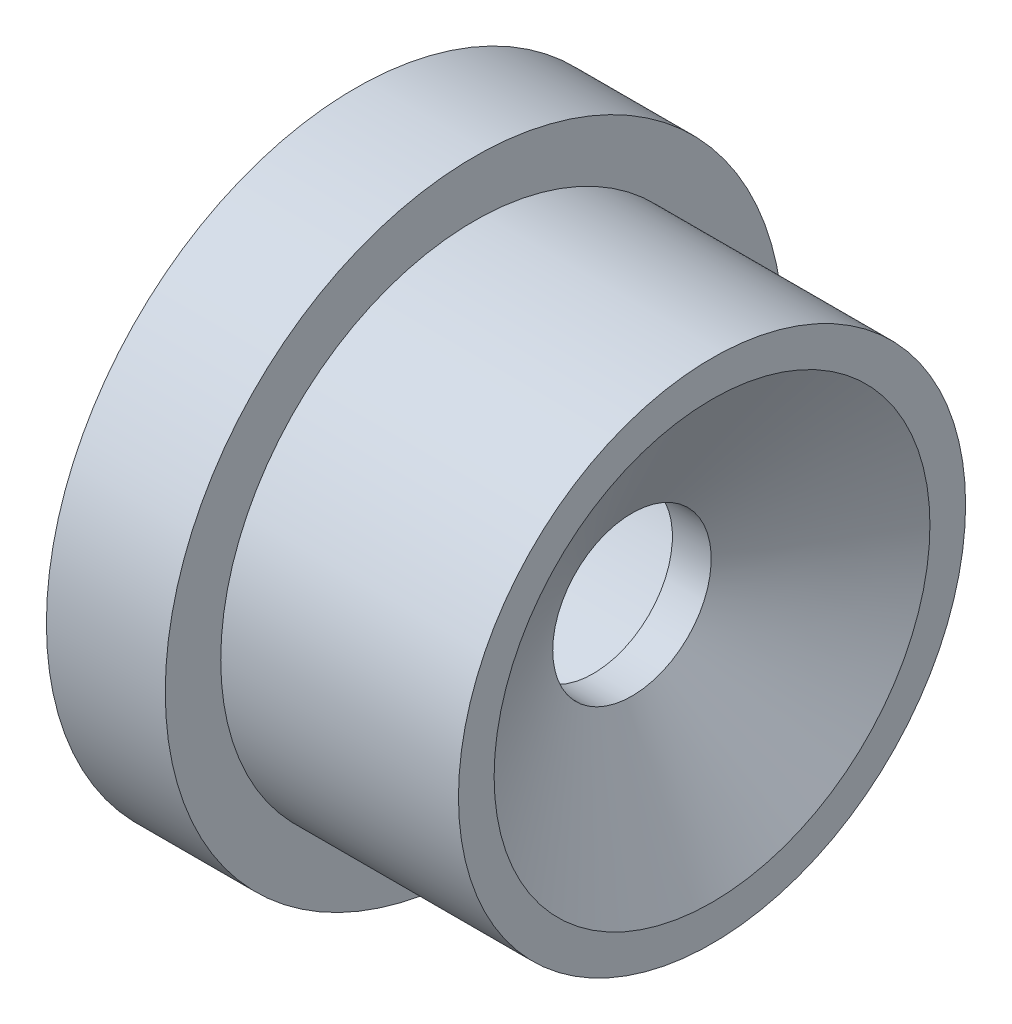
from build123d import *


with BuildPart() as part:
    # Эскиз1 → Повернуть1 (revolve)
    with BuildSketch(Plane.XY):
        Polygon((0, 2.25), (3, 2.25), (3, 1), (3.489637029, 1), (4.5, 2.75), (4.5, 3.2), (1.5, 3.2), (1.5, 3.9), (0, 3.9), align=None)
    revolve(axis=Axis((0, 0, 0), (1, 0, 0)))


solid = part.part
